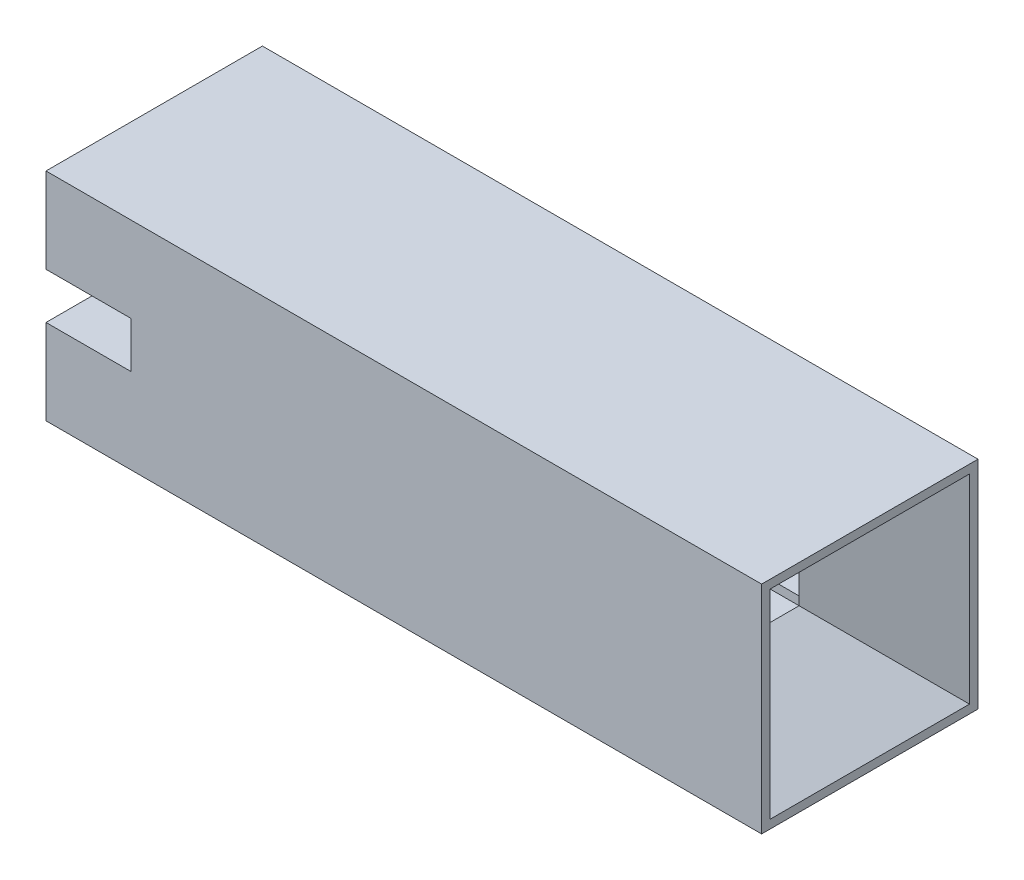
from build123d import *

# Parameters (mm, degrees)
SKETCH1_W           = 8.4
SKETCH1_H           = 2.54
BOSS_EXTRUDE1_DEPTH = 2.54
CUT_EXTRUDE1_REACH  = 10.4
SKETCH2_W           = 0.74
SKETCH2_H           = 0.74
CHAMFER2_SIZE       = 0.8
CHAMFER2_SIZE2      = 1.2
SKETCH3_W           = 2.54
SKETCH3_H           = 0.54
CUT_EXTRUDE2_DEPTH  = 1
CUT_EXTRUDE4_START  = -6.2
SKETCH5_W           = 1.74
SKETCH5_H           = 0.54
CUT_EXTRUDE4_DEPTH  = 6.2


with BuildPart() as part:
    # Sketch1 → Boss-Extrude1 (new body)
    with BuildSketch(Plane.XY):
        with Locations((4.2, 1.27)):
            Rectangle(SKETCH1_W, SKETCH1_H)
    extrude(amount=BOSS_EXTRUDE1_DEPTH)

    # Sketch2 → Cut-Extrude1 (cut, up to next)
    with BuildSketch(Plane(origin=(8.4, 0, 0), x_dir=(0, 0, -1), z_dir=(1, 0, 0)), mode=Mode.PRIVATE) as cut_extrude1_sk1:
        with Locations((-1.27, 1.27)):
            Rectangle(SKETCH2_W, SKETCH2_H)
    cut_extrude1_tool1 = extrude(cut_extrude1_sk1.sketch, amount=-CUT_EXTRUDE1_REACH, mode=Mode.PRIVATE) & part.part
    add(cut_extrude1_tool1.solids().sort_by_distance((8.4, 1.27, 1.27))[0], mode=Mode.SUBTRACT)

    # Chamfer2
    chamfer2_edges = [part.edges().sort_by_distance(p)[0] for p in [
        (8.4, 1.27, 1.64),
        (8.4, 0.9, 1.27),
        (8.4, 1.27, 0.9),
        (8.4, 1.64, 1.27),
    ]]
    chamfer2_side = [part.faces().sort_by_distance(p)[0] for p in [
        (8.4, 0.035921024, 1.27),
    ]]
    chamfer(chamfer2_edges, length=CHAMFER2_SIZE, length2=CHAMFER2_SIZE2, reference=chamfer2_side[0])

    # Sketch3 → Cut-Extrude2 (cut)
    with BuildSketch(Plane.ZY):
        with Locations((1.27, 1.27)):
            Rectangle(SKETCH3_W, SKETCH3_H)
    extrude(amount=-CUT_EXTRUDE2_DEPTH, mode=Mode.SUBTRACT)

    # Sketch5 → Cut-Extrude4 (cut)
    with BuildSketch(Plane.ZY.offset(-1).offset(CUT_EXTRUDE4_START)):
        with Locations((1.27, 1.27)):
            Rectangle(SKETCH5_W, SKETCH5_H)
    extrude(amount=CUT_EXTRUDE4_DEPTH, mode=Mode.SUBTRACT)


solid = part.part
